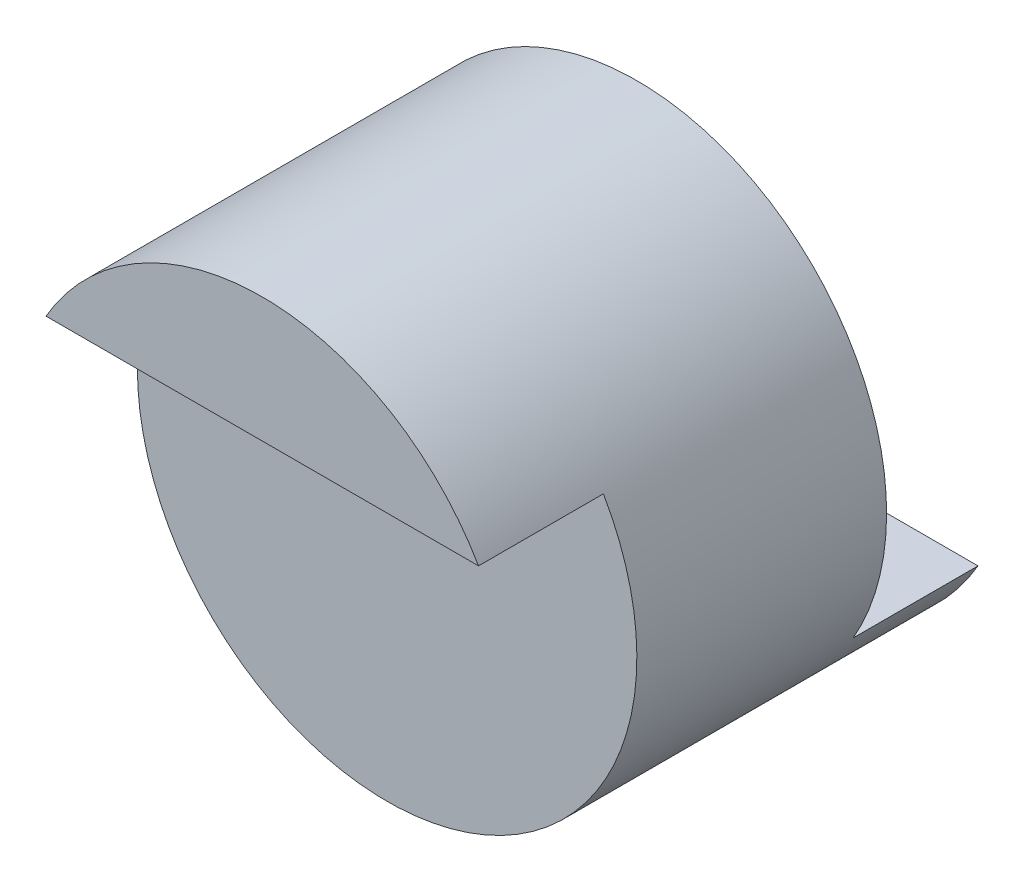
from build123d import *

# Parameters (mm, degrees)
SKETCH1_R           = 2
BOSS_EXTRUDE1_DEPTH = 2
BOSS_EXTRUDE2_DEPTH = 1
BOSS_EXTRUDE3_DEPTH = 1


with BuildPart() as part:
    # Sketch1 → Boss-Extrude1 (new body)
    with BuildSketch(Plane.XY):
        Circle(SKETCH1_R)
    extrude(amount=BOSS_EXTRUDE1_DEPTH)

    # Sketch2 → Boss-Extrude2 (add)
    with BuildSketch(Plane.XY.offset(2)):
        with BuildLine():
            Line((-1.732050808, 1), (1.732050808, 1))
            ThreePointArc((1.732050808, 1), (0, 2), (-1.732050808, 1))
        make_face()
    extrude(amount=BOSS_EXTRUDE2_DEPTH)

    # Sketch3 → Boss-Extrude3 (add)
    with BuildSketch(Plane(origin=(0, 0, 0), x_dir=(-1, 0, 0), z_dir=(0, 0, -1))):
        with BuildLine():
            Line((1.732050808, -1), (-1.732050808, -1))
            ThreePointArc((-1.732050808, -1), (0, -2), (1.732050808, -1))
        make_face()
    extrude(amount=BOSS_EXTRUDE3_DEPTH)


solid = part.part
